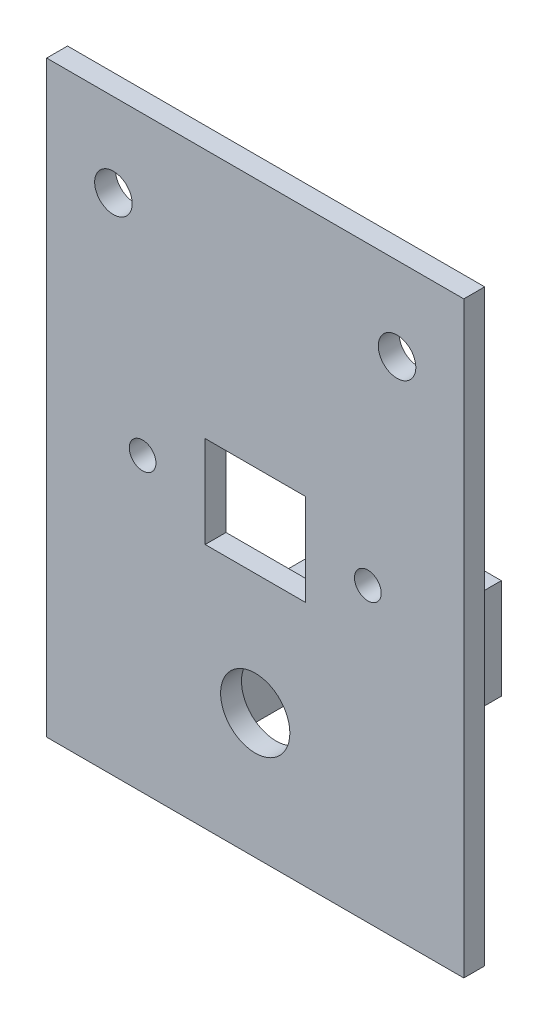
from build123d import *

# Parameters (mm, degrees)
SKETCH1_W           = 50
SKETCH1_H           = 70.5
SKETCH1_R           = 2.25
SKETCH1_R_2         = 1.6
SKETCH1_R_3         = 4.15
SKETCH1_W_2         = 12
SKETCH1_H_2         = 11
BOSS_EXTRUDE1_DEPTH = 2.5
SKETCH2_W           = 2
SKETCH2_H           = 12
BOSS_EXTRUDE2_DEPTH = 20


with BuildPart() as part:
    # Sketch1 → Boss-Extrude1 (new body)
    with BuildSketch(Plane.XY):
        Rectangle(SKETCH1_W, SKETCH1_H)
        with Locations((-17, 25.25)):
            Circle(SKETCH1_R, mode=Mode.SUBTRACT)
        with Locations((17, 25.25)):
            Circle(SKETCH1_R, mode=Mode.SUBTRACT)
        with Locations((-13.5, -0.25)):
            Circle(SKETCH1_R_2, mode=Mode.SUBTRACT)
        with Locations((13.5, -0.25)):
            Circle(SKETCH1_R_2, mode=Mode.SUBTRACT)
        with Locations((0, -20.25)):
            Circle(SKETCH1_R_3, mode=Mode.SUBTRACT)
        with Locations((0, -0.25)):
            Rectangle(SKETCH1_W_2, SKETCH1_H_2, mode=Mode.SUBTRACT)
    extrude(amount=BOSS_EXTRUDE1_DEPTH)

    # Sketch2 → Boss-Extrude2 (add)
    with BuildSketch(Plane(origin=(0, 0, 0), x_dir=(-1, 0, 0), z_dir=(0, 0, -1))):
        with Locations((6, -20.25)):
            Rectangle(SKETCH2_W, SKETCH2_H)
        with Locations((-6, -20.25)):
            Rectangle(SKETCH2_W, SKETCH2_H)
    extrude(amount=BOSS_EXTRUDE2_DEPTH)


solid = part.part
